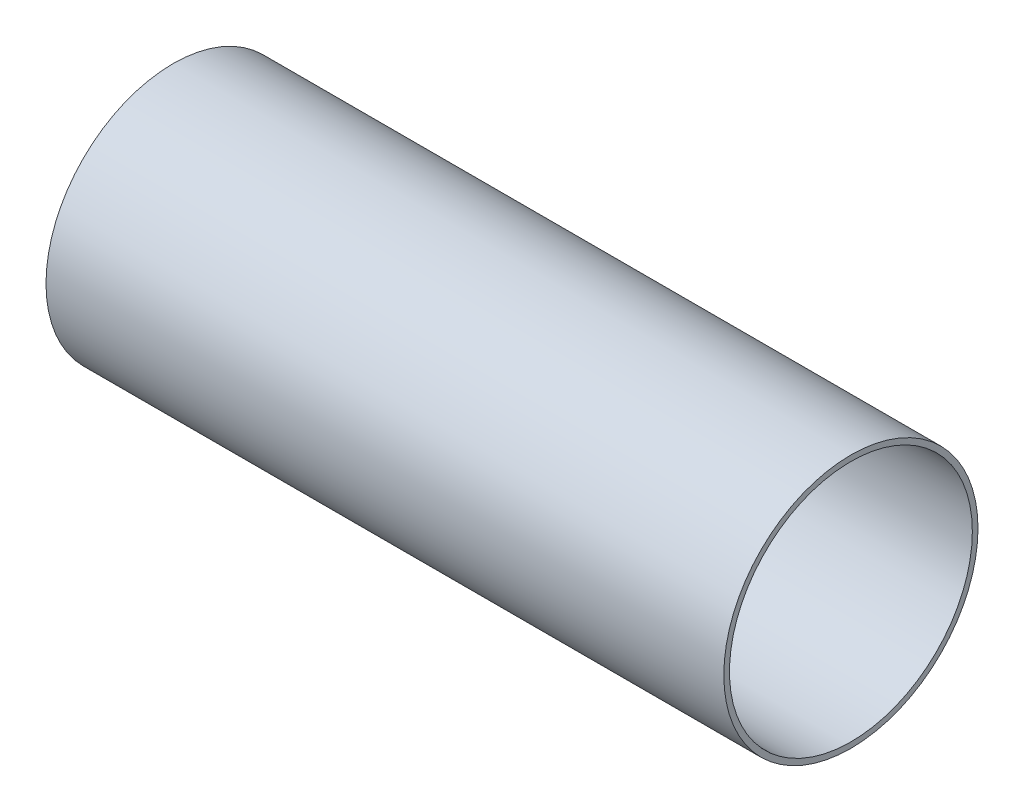
from build123d import *

# Parameters (mm, degrees)
SKETCH1_R           = 571.501143002
SKETCH1_R_2         = 546.101092202
BOSS_EXTRUDE1_DEPTH = 1524.003048006


with BuildPart() as part:
    # Sketch1 → Boss-Extrude1 (new body, symmetric)
    with BuildSketch(Plane(origin=(0, 0, 0), x_dir=(0, 0, -1), z_dir=(1, 0, 0))):
        Circle(SKETCH1_R)
        Circle(SKETCH1_R_2, mode=Mode.SUBTRACT)
    extrude(amount=BOSS_EXTRUDE1_DEPTH, both=True)


solid = part.part
